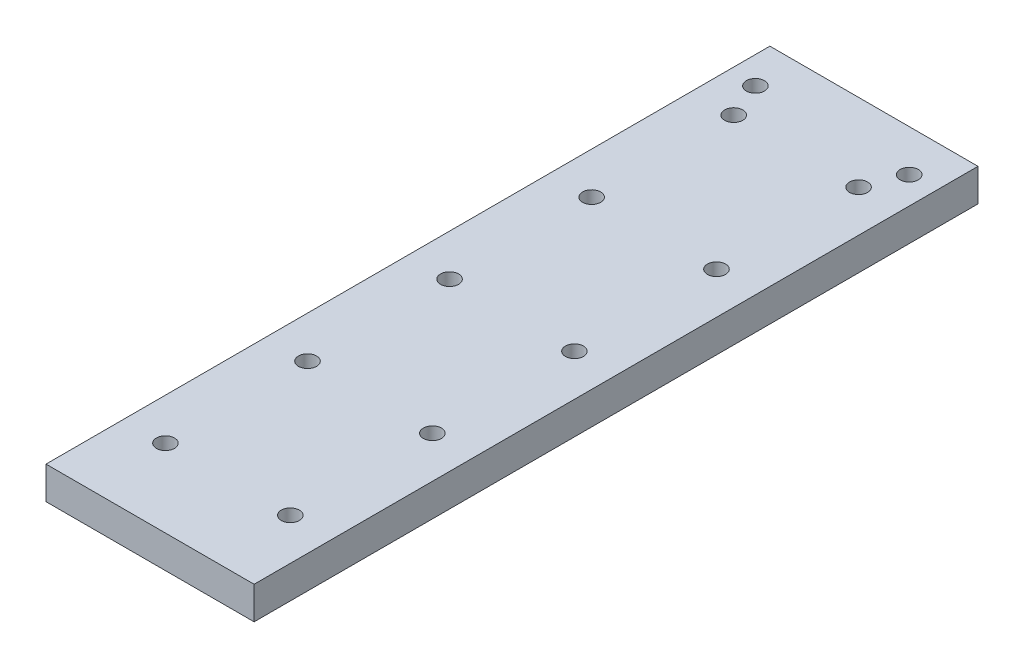
from build123d import *

# Parameters (mm, degrees)
SKETCH1_W           = 115
SKETCH1_H           = 400
BOSS_EXTRUDE1_DEPTH = 18
SKETCH2_R           = 5
CUT_EXTRUDE1_DEPTH  = 19


with BuildPart() as part:
    # Sketch1 → Boss-Extrude1 (new body)
    with BuildSketch(Plane(origin=(0, 0, 0), x_dir=(1, 0, 0), z_dir=(0, 1, 0))):
        Rectangle(SKETCH1_W, SKETCH1_H)
    extrude(amount=BOSS_EXTRUDE1_DEPTH)

    # Sketch2 → Cut-Extrude1 (cut, through all)
    with BuildSketch(Plane(origin=(0, 18, 0), x_dir=(1, 0, 0), z_dir=(0, 1, 0))):
        with Locations((-42.5, 177)):
            Circle(SKETCH2_R)
        with Locations((42.5, 177)):
            Circle(SKETCH2_R)
        with Locations((34.5, 157)):
            Circle(SKETCH2_R)
        with Locations((34.5, 78.5)):
            Circle(SKETCH2_R)
        with Locations((34.5, 0)):
            Circle(SKETCH2_R)
        with Locations((34.5, -78.5)):
            Circle(SKETCH2_R)
        with Locations((34.5, -157)):
            Circle(SKETCH2_R)
        with Locations((-34.5, -157)):
            Circle(SKETCH2_R)
        with Locations((-34.5, -78.5)):
            Circle(SKETCH2_R)
        with Locations((-34.5, 0)):
            Circle(SKETCH2_R)
        with Locations((-34.5, 78.5)):
            Circle(SKETCH2_R)
        with Locations((-34.5, 157)):
            Circle(SKETCH2_R)
    extrude(amount=-CUT_EXTRUDE1_DEPTH, mode=Mode.SUBTRACT)


solid = part.part
